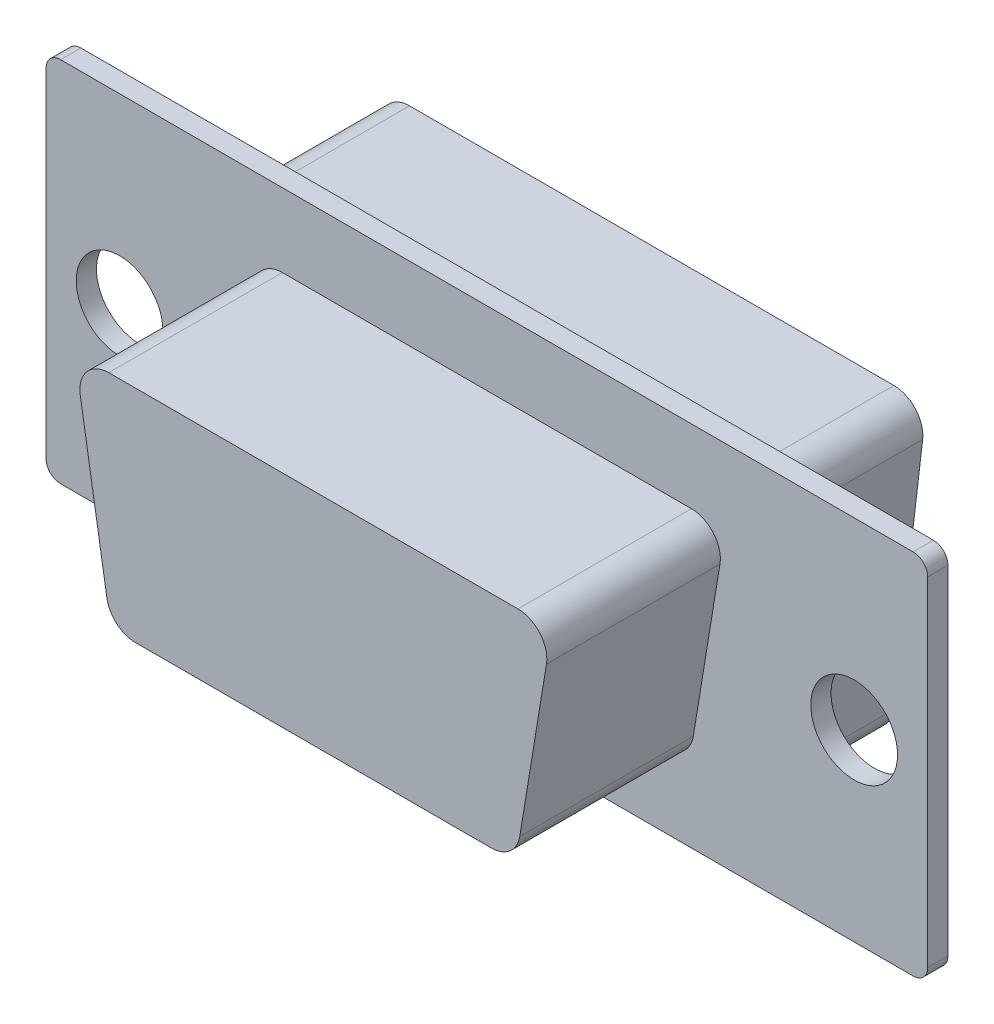
from build123d import *

# Parameters (mm, degrees)
ESQUISSE1_W             = 30.48
ESQUISSE1_H             = 12.7
BOSS_EXTRU_1_DEPTH      = 0.7
CONG_1_R                = 0.5
ESQUISSE2_R             = 1.5
ENL_V_MAT_EXTRU_1_DEPTH = 1.7
BOSS_EXTRU_2_DEPTH      = 6
CONG_2_R                = 1
BOSS_EXTRU_3_DEPTH      = 5
CONG_3_R                = 1


with BuildPart() as part:
    # Esquisse1 → Boss.-Extru.1 (new body)
    with BuildSketch(Plane.XY):
        Rectangle(ESQUISSE1_W, ESQUISSE1_H)
    extrude(amount=BOSS_EXTRU_1_DEPTH)

    # Congé1
    cong_1_edges = [part.edges().sort_by_distance(p)[0] for p in [
        (-15.24, 6.35, 0.35),
        (15.24, 6.35, 0.35),
        (15.24, -6.35, 0.35),
        (-15.24, -6.35, 0.35),
    ]]
    fillet(cong_1_edges, radius=CONG_1_R)

    # Esquisse2 → Enlèv. mat.-Extru.1 (cut, through all)
    with BuildSketch(Plane.XY.offset(0.7)):
        with Locations((-12.7, 0)):
            Circle(ESQUISSE2_R)
        with Locations((12.7, 0)):
            Circle(ESQUISSE2_R)
    extrude(amount=-ENL_V_MAT_EXTRU_1_DEPTH, mode=Mode.SUBTRACT)

    # Esquisse3 → Boss.-Extru.2 (add)
    with BuildSketch(Plane.XY.offset(0.7)):
        Polygon((-8.25, 3.81), (8.25, 3.81), (7, -3.81), (-7, -3.81), align=None)
    extrude(amount=BOSS_EXTRU_2_DEPTH)

    # Congé2
    cong_2_edges = [part.edges().sort_by_distance(p)[0] for p in [
        (-8.25, 3.81, 3.7),
        (-7, -3.81, 3.7),
        (7, -3.81, 3.7),
        (8.25, 3.81, 3.7),
    ]]
    fillet(cong_2_edges, radius=CONG_2_R)

    # Esquisse4 → Boss.-Extru.3 (add)
    with BuildSketch(Plane(origin=(0, 0, 0), x_dir=(-1, 0, 0), z_dir=(0, 0, -1))):
        Polygon((-9.5, 5.3), (9.5, 5.3), (8.25, -5.3), (-8.25, -5.3), align=None)
    extrude(amount=BOSS_EXTRU_3_DEPTH)

    # Congé3
    cong_3_edges = [part.edges().sort_by_distance(p)[0] for p in [
        (9.5, 5.3, -2.5),
        (8.25, -5.3, -2.5),
        (-8.25, -5.3, -2.5),
        (-9.5, 5.3, -2.5),
    ]]
    fillet(cong_3_edges, radius=CONG_3_R)


solid = part.part
